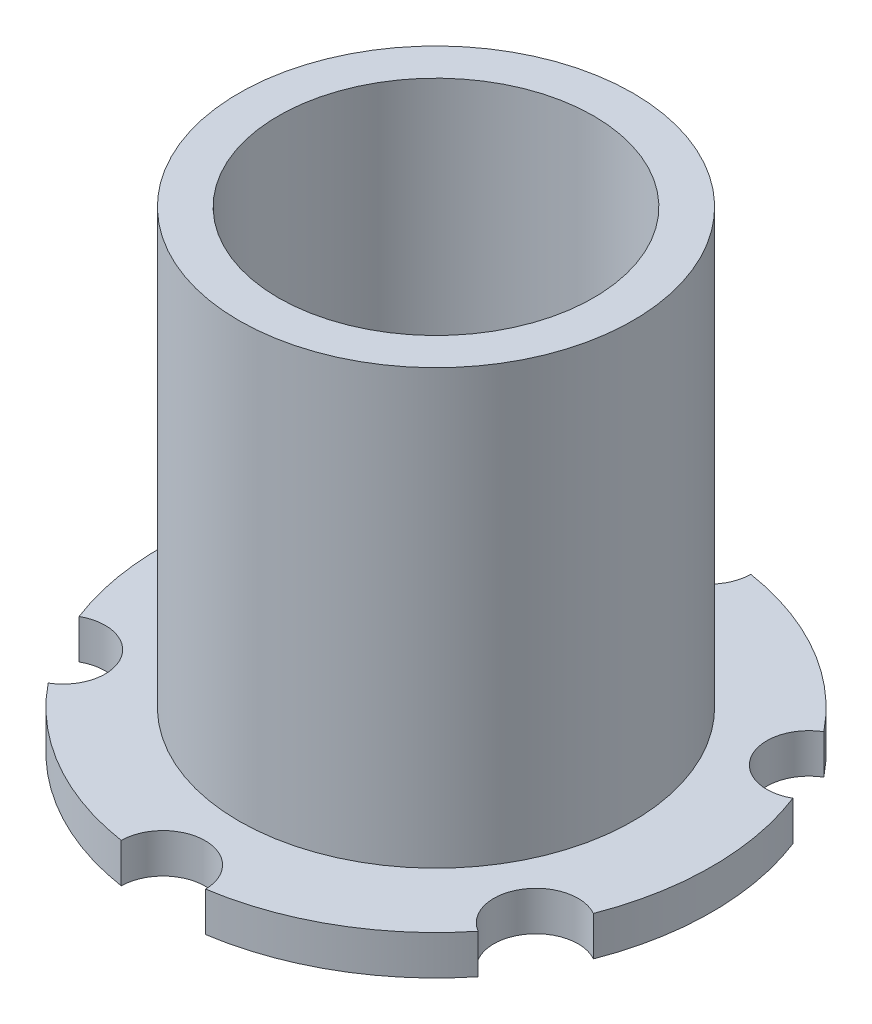
from build123d import *

# Parameters (mm, degrees)
SKETCH2_R            = 7.9375
SKETCH2_R_2          = 6.35
BOSS_EXTRUDE1_DEPTH  = 19.05
SKETCH3_R            = 11.1125
SKETCH3_R_2          = 7.9375
BOSS_EXTRUDE2_DEPTH  = 1.5875
M3_CLEARANCE_HOLE1_D = 3.4
CIRPATTERN1_COUNT    = 6


with BuildPart() as part:
    # Sketch2 → Boss-Extrude1 (new body)
    with BuildSketch(Plane(origin=(0, 0, 0), x_dir=(1, 0, 0), z_dir=(0, 1, 0))):
        Circle(SKETCH2_R)
        Circle(SKETCH2_R_2, mode=Mode.SUBTRACT)
    extrude(amount=BOSS_EXTRUDE1_DEPTH)

    # Sketch3 → Boss-Extrude2 (add)
    with BuildSketch(Plane(origin=(0, 0, 0), x_dir=(1, 0, 0), z_dir=(0, 1, 0))):
        Circle(SKETCH3_R)
        Circle(SKETCH3_R_2, mode=Mode.SUBTRACT)
    extrude(amount=BOSS_EXTRUDE2_DEPTH)

    # M3 Clearance Hole1 (through all)
    with Locations(Plane(origin=(0, 0, 0), x_dir=(-1, 0, 0), z_dir=(0, -1, 0))):
        with Locations((0, -11)):
            m3_clearance_hole1 = Hole(M3_CLEARANCE_HOLE1_D / 2)

    # CirPattern1: M3 Clearance Hole1 ×6 about axis
    cirpattern1_axis = Axis((0, 0, 0), (0, 1, 0))
    for i in range(1, CIRPATTERN1_COUNT):
        add(m3_clearance_hole1.rotate(cirpattern1_axis, i * 360 / CIRPATTERN1_COUNT), mode=Mode.SUBTRACT)


solid = part.part
